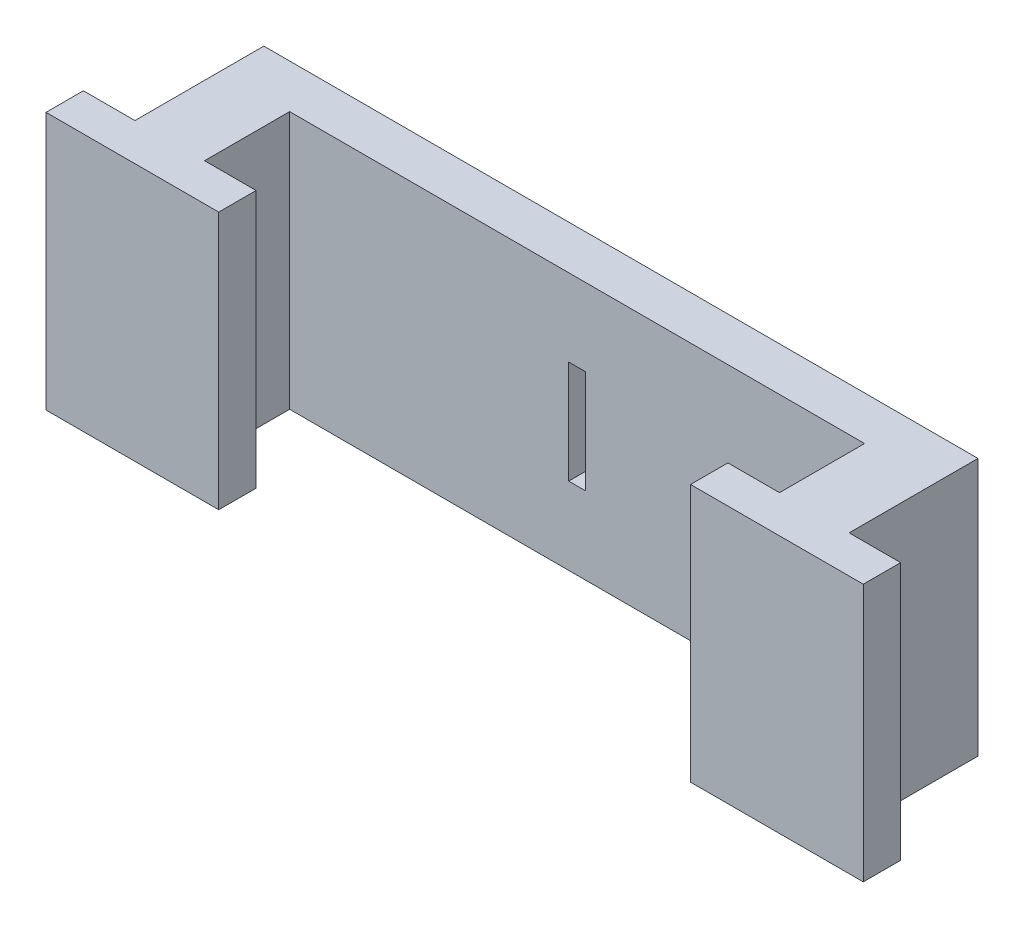
from build123d import *

# Parameters (mm, degrees)
BOSS_EXTRUDE1_DEPTH = 10
CUT_EXTRUDE2_DEPTH  = 11
SKETCH3_W           = 0.65
SKETCH3_H           = 4
CUT_EXTRUDE3_DEPTH  = 7.45


with BuildPart() as part:
    # Sketch1 → Boss-Extrude1 (new body)
    with BuildSketch(Plane(origin=(0, 0, 0), x_dir=(1, 0, 0), z_dir=(0, 1, 0))):
        Polygon((1.5, 1.75), (3.5, 1.75), (3.5, 0), (-3.5, 0), (-3.5, 1.75), (-1.5, 1.75), (-1.5, 6.75), (1.5, 6.75), (23.5, 6.75), (26.5, 6.75), (26.5, 1.75), (28.5, 1.75), (28.5, 0), (21.5, 0), (21.5, 1.75), (23.5, 1.75), (23.5, 4.75), (1.5, 4.75), align=None)
    extrude(amount=BOSS_EXTRUDE1_DEPTH)

    # Sketch2 → Cut-Extrude2 (cut, through all)
    with BuildSketch(Plane(origin=(0, 10, 0), x_dir=(1, 0, 0), z_dir=(0, 1, 0))):
        Polygon((-3.65, 1.9), (-3.65, -0.15), (3.65, -0.15), (3.65, 1.9), (1.65, 1.9), (1.65, 4.6), (23.35, 4.6), (23.35, 1.9), (21.35, 1.9), (21.35, -0.15), (28.65, -0.15), (28.65, 1.9), (26.65, 1.9), (26.65, 6.9), (-1.65, 6.9), (-1.65, 1.9), align=None)
        Polygon((-3.35, 1.6), (-3.35, 0.15), (3.35, 0.15), (3.35, 1.6), (1.35, 1.6), (1.35, 4.9), (23.65, 4.9), (23.65, 1.6), (21.65, 1.6), (21.65, 0.15), (28.35, 0.15), (28.35, 1.6), (26.35, 1.6), (26.35, 6.6), (-1.35, 6.6), (-1.35, 1.6), align=None, mode=Mode.SUBTRACT)
    extrude(amount=-CUT_EXTRUDE2_DEPTH, mode=Mode.SUBTRACT)

    # Sketch3 → Cut-Extrude3 (cut, through all)
    with BuildSketch(Plane(origin=(0, 0, -6.6), x_dir=(-1, 0, 0), z_dir=(0, 0, -1))):
        with Locations((-12.5, 5)):
            Rectangle(SKETCH3_W, SKETCH3_H)
    extrude(amount=-CUT_EXTRUDE3_DEPTH, mode=Mode.SUBTRACT)


solid = part.part
